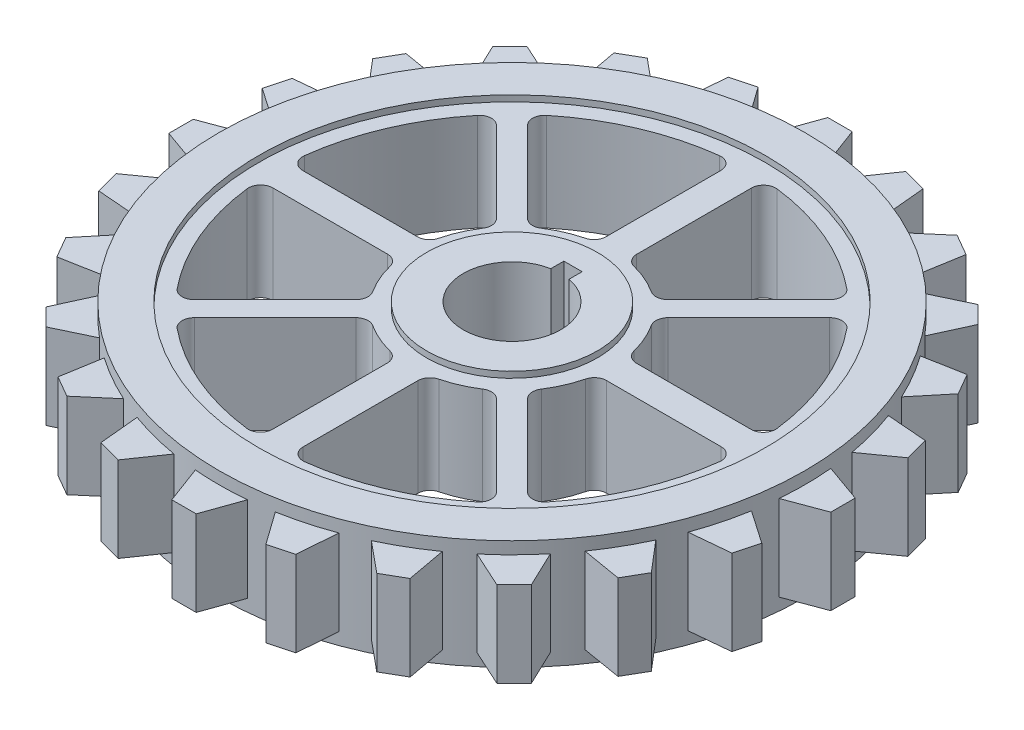
from build123d import *

# Parameters (mm, degrees)
SKETCH1_R           = 41.525000065
BOSS_EXTRUDE1_DEPTH = 9
BOSS_EXTRUDE2_DEPTH = 7
BOSS_EXTRUDE3_DEPTH = 7
BOSS_EXTRUDE4_DEPTH = 7
SKETCH1_11_R        = 14
BOSS_EXTRUDE5_DEPTH = 9
SKETCH1_12_R        = 41.525000065
SKETCH1_12_R_2      = 14
BOSS_EXTRUDE6_DEPTH = 8


with BuildPart() as part:
    # Sketch1 → Boss-Extrude1 (new, symmetric)
    with BuildSketch(Plane(origin=(0, 0, 0), x_dir=(1, 0, 0), z_dir=(0, 1, 0))):
        with BuildLine():
            ThreePointArc((8.078062241, 47.340738711), (6.072143554, 47.639581274), (4.055396381, 47.853467915))
            ThreePointArc((4.055396381, 47.853467915), (-0.198017618, 48.024591829), (-4.449875843, 47.818398512))
            ThreePointArc((-4.449875843, 47.818398512), (-6.464790654, 47.587888302), (-8.46817677, 47.272514355))
            ThreePointArc((-8.46817677, 47.272514355), (-12.62094933, 46.336942813), (-16.674562241, 45.037313478))
            ThreePointArc((-16.674562241, 45.037313478), (-18.561160063, 44.293159386), (-20.414657669, 43.470017064))
            ThreePointArc((-20.414657669, 43.470017064), (-24.183784202, 41.491507721), (-27.762904779, 39.187009959))
            ThreePointArc((-27.762904779, 39.187009959), (-29.392617088, 37.979924855), (-30.969913384, 36.705109948))
            ThreePointArc((-30.969913384, 36.705109948), (-34.098534146, 33.818494945), (-36.959251237, 30.66617647))
            ThreePointArc((-36.959251237, 30.66617647), (-38.221015831, 29.07842121), (-39.414620683, 27.438810246))
            ThreePointArc((-39.414620683, 27.438810246), (-41.689525339, 23.840807627), (-43.636885801, 20.055493733))
            ThreePointArc((-43.636885801, 20.055493733), (-44.444715509, 18.195271215), (-45.173286717, 16.302600971))
            ThreePointArc((-45.173286717, 16.302600971), (-46.439444275, 12.238408667), (-47.340738711, 8.078062241))
            ThreePointArc((-47.340738711, 8.078062241), (-47.639581274, 6.072143554), (-47.853467915, 4.055396381))
            ThreePointArc((-47.853467915, 4.055396381), (-48.024591829, -0.198017618), (-47.818398512, -4.449875843))
            ThreePointArc((-47.818398512, -4.449875843), (-47.587888302, -6.464790654), (-47.272514355, -8.46817677))
            ThreePointArc((-47.272514355, -8.46817677), (-46.336942813, -12.62094933), (-45.037313478, -16.674562241))
            ThreePointArc((-45.037313478, -16.674562241), (-44.293159386, -18.561160063), (-43.470017064, -20.414657669))
            ThreePointArc((-43.470017064, -20.414657669), (-41.491507721, -24.183784202), (-39.187009959, -27.762904779))
            ThreePointArc((-39.187009959, -27.762904779), (-37.979924855, -29.392617088), (-36.705109948, -30.969913384))
            ThreePointArc((-36.705109948, -30.969913384), (-33.818494945, -34.098534146), (-30.66617647, -36.959251237))
            ThreePointArc((-30.66617647, -36.959251237), (-29.07842121, -38.221015831), (-27.438810246, -39.414620683))
            ThreePointArc((-27.438810246, -39.414620683), (-23.840807627, -41.689525339), (-20.055493733, -43.636885801))
            ThreePointArc((-20.055493733, -43.636885801), (-18.195271215, -44.444715509), (-16.302600971, -45.173286717))
            ThreePointArc((-16.302600971, -45.173286717), (-12.238408667, -46.439444275), (-8.078062241, -47.340738711))
            ThreePointArc((-8.078062241, -47.340738711), (-6.072143554, -47.639581274), (-4.055396381, -47.853467915))
            ThreePointArc((-4.055396381, -47.853467915), (0.198017618, -48.024591829), (4.449875843, -47.818398512))
            ThreePointArc((4.449875843, -47.818398512), (6.464790654, -47.587888302), (8.46817677, -47.272514355))
            ThreePointArc((8.46817677, -47.272514355), (12.62094933, -46.336942813), (16.674562241, -45.037313478))
            ThreePointArc((16.674562241, -45.037313478), (18.561160063, -44.293159386), (20.414657669, -43.470017064))
            ThreePointArc((20.414657669, -43.470017064), (24.183784202, -41.491507721), (27.762904779, -39.187009959))
            ThreePointArc((27.762904779, -39.187009959), (29.392617088, -37.979924855), (30.969913384, -36.705109948))
            ThreePointArc((30.969913384, -36.705109948), (34.098534146, -33.818494945), (36.959251237, -30.66617647))
            ThreePointArc((36.959251237, -30.66617647), (38.221015831, -29.07842121), (39.414620683, -27.438810246))
            ThreePointArc((39.414620683, -27.438810246), (41.689525339, -23.840807627), (43.636885801, -20.055493733))
            ThreePointArc((43.636885801, -20.055493733), (44.444715509, -18.195271215), (45.173286717, -16.302600971))
            ThreePointArc((45.173286717, -16.302600971), (46.439444275, -12.238408667), (47.340738711, -8.078062241))
            ThreePointArc((47.340738711, -8.078062241), (47.639581274, -6.072143554), (47.853467915, -4.055396381))
            ThreePointArc((47.853467915, -4.055396381), (47.982097865, -2.029511215), (48.025000065, 0))
            ThreePointArc((48.025000065, 0), (47.973321872, 2.227334686), (47.818398512, 4.449875843))
            ThreePointArc((47.818398512, 4.449875843), (47.587888302, 6.464790654), (47.272514355, 8.46817677))
            ThreePointArc((47.272514355, 8.46817677), (46.336942813, 12.62094933), (45.037313478, 16.674562241))
            ThreePointArc((45.037313478, 16.674562241), (44.293159386, 18.561160063), (43.470017064, 20.414657669))
            ThreePointArc((43.470017064, 20.414657669), (41.491507721, 24.183784202), (39.187009959, 27.762904779))
            ThreePointArc((39.187009959, 27.762904779), (37.979924855, 29.392617088), (36.705109948, 30.969913384))
            ThreePointArc((36.705109948, 30.969913384), (33.818494945, 34.098534146), (30.66617647, 36.959251237))
            ThreePointArc((30.66617647, 36.959251237), (29.07842121, 38.221015831), (27.438810246, 39.414620683))
            ThreePointArc((27.438810246, 39.414620683), (23.840807627, 41.689525339), (20.055493733, 43.636885801))
            ThreePointArc((20.055493733, 43.636885801), (18.195271215, 44.444715509), (16.302600971, 45.173286717))
            ThreePointArc((16.302600971, 45.173286717), (12.238408667, 46.439444275), (8.078062241, 47.340738711))
        make_face()
        Circle(SKETCH1_R, mode=Mode.SUBTRACT)
    extrude(amount=BOSS_EXTRUDE1_DEPTH, both=True)

    # Sketch1_8 → Boss-Extrude2 (add, symmetric)
    with BuildSketch(Plane(origin=(0, 0, 0), x_dir=(1, 0, 0), z_dir=(0, 1, 0))):
        with BuildLine():
            Line((11.813793694, 52.765299234), (8.078062241, 47.340738711))
            ThreePointArc((8.078062241, 47.340738711), (12.238408667, 46.439444275), (16.302600971, 45.173286717))
            Line((16.302600971, 45.173286717), (15.677497, 51.730023054))
            Line((15.677497, 51.730023054), (11.813793694, 52.765299234))
        make_face()
        with BuildLine():
            Line((25.067912798, 47.909730459), (20.055493733, 43.636885801))
            ThreePointArc((20.055493733, 43.636885801), (23.840807627, 41.689525339), (27.438810246, 39.414620683))
            Line((27.438810246, 39.414620683), (28.532014413, 45.909730459))
            Line((28.532014413, 45.909730459), (25.067912798, 47.909730459))
        make_face()
        with BuildLine():
            Line((36.613695072, 39.789192728), (30.66617647, 36.959251237))
            ThreePointArc((30.66617647, 36.959251237), (33.818494945, 34.098534146), (36.705109948, 30.969913384))
            Line((36.705109948, 30.969913384), (39.442122196, 36.960765603))
            Line((39.442122196, 36.960765603), (36.613695072, 39.789192728))
        make_face()
        with BuildLine():
            Line((45.664314533, 28.957087267), (39.187009959, 27.762904779))
            ThreePointArc((39.187009959, 27.762904779), (41.491507721, 24.183784202), (43.470017064, 20.414657669))
            Line((43.470017064, 20.414657669), (47.664314533, 25.492985652))
            Line((47.664314533, 25.492985652), (45.664314533, 28.957087267))
        make_face()
        with BuildLine():
            Line((51.602986422, 16.151604163), (45.037313478, 16.674562241))
            ThreePointArc((45.037313478, 16.674562241), (46.336942813, 12.62094933), (47.272514355, 8.46817677))
            Line((47.272514355, 8.46817677), (52.638262603, 12.287900858))
            Line((52.638262603, 12.287900858), (51.602986422, 16.151604163))
        make_face()
    extrude(amount=BOSS_EXTRUDE2_DEPTH, both=True)

    # Sketch1_9 → Boss-Extrude3 (add, symmetric)
    with BuildSketch(Plane(origin=(0, 0, 0), x_dir=(1, 0, 0), z_dir=(0, 1, 0))):
        with BuildLine():
            Line((1.754584074, 54.025000065), (-2.245415926, 54.025000065))
            Line((-2.245415926, 54.025000065), (-4.449875843, 47.818398512))
            ThreePointArc((-4.449875843, 47.818398512), (-0.198017618, 48.024591829), (4.055396381, 47.853467915))
            Line((4.055396381, 47.853467915), (1.754584074, 54.025000065))
        make_face()
        with BuildLine():
            ThreePointArc((-16.674562241, 45.037313478), (-12.62094933, 46.336942813), (-8.46817677, 47.272514355))
            Line((-8.46817677, 47.272514355), (-12.287900858, 52.638262603))
            Line((-12.287900858, 52.638262603), (-16.151604163, 51.602986422))
            Line((-16.151604163, 51.602986422), (-16.674562241, 45.037313478))
        make_face()
        with BuildLine():
            ThreePointArc((-27.762904779, 39.187009959), (-24.183784202, 41.491507721), (-20.414657669, 43.470017064))
            Line((-20.414657669, 43.470017064), (-25.492985652, 47.664314533))
            Line((-25.492985652, 47.664314533), (-28.957087267, 45.664314533))
            Line((-28.957087267, 45.664314533), (-27.762904779, 39.187009959))
        make_face()
        with BuildLine():
            ThreePointArc((-36.959251237, 30.66617647), (-34.098534146, 33.818494945), (-30.969913384, 36.705109948))
            Line((-30.969913384, 36.705109948), (-36.960765603, 39.442122196))
            Line((-36.960765603, 39.442122196), (-39.789192728, 36.613695072))
            Line((-39.789192728, 36.613695072), (-36.959251237, 30.66617647))
        make_face()
        with BuildLine():
            ThreePointArc((-43.636885801, 20.055493733), (-41.689525339, 23.840807627), (-39.414620683, 27.438810246))
            Line((-39.414620683, 27.438810246), (-45.909730459, 28.532014413))
            Line((-45.909730459, 28.532014413), (-47.909730459, 25.067912798))
            Line((-47.909730459, 25.067912798), (-43.636885801, 20.055493733))
        make_face()
        with BuildLine():
            ThreePointArc((-47.340738711, 8.078062241), (-46.439444275, 12.238408667), (-45.173286717, 16.302600971))
            Line((-45.173286717, 16.302600971), (-51.730023054, 15.677497))
            Line((-51.730023054, 15.677497), (-52.765299234, 11.813793694))
            Line((-52.765299234, 11.813793694), (-47.340738711, 8.078062241))
        make_face()
        with BuildLine():
            ThreePointArc((-47.818398512, -4.449875843), (-48.024591829, -0.198017618), (-47.853467915, 4.055396381))
            Line((-47.853467915, 4.055396381), (-54.025000065, 1.754584074))
            Line((-54.025000065, 1.754584074), (-54.025000065, -2.245415926))
            Line((-54.025000065, -2.245415926), (-47.818398512, -4.449875843))
        make_face()
        with BuildLine():
            ThreePointArc((-45.037313478, -16.674562241), (-46.336942813, -12.62094933), (-47.272514355, -8.46817677))
            Line((-47.272514355, -8.46817677), (-52.638262603, -12.287900858))
            Line((-52.638262603, -12.287900858), (-51.602986422, -16.151604163))
            Line((-51.602986422, -16.151604163), (-45.037313478, -16.674562241))
        make_face()
        with BuildLine():
            Line((52.765299234, -11.813793694), (47.340738711, -8.078062241))
            ThreePointArc((47.340738711, -8.078062241), (46.439444275, -12.238408667), (45.173286717, -16.302600971))
            Line((45.173286717, -16.302600971), (51.730023054, -15.677497))
            Line((51.730023054, -15.677497), (52.765299234, -11.813793694))
        make_face()
        with BuildLine():
            ThreePointArc((-39.187009959, -27.762904779), (-41.491507721, -24.183784202), (-43.470017064, -20.414657669))
            Line((-43.470017064, -20.414657669), (-47.664314533, -25.492985652))
            Line((-47.664314533, -25.492985652), (-45.664314533, -28.957087267))
            Line((-45.664314533, -28.957087267), (-39.187009959, -27.762904779))
        make_face()
        with BuildLine():
            Line((47.909730459, -25.067912798), (43.636885801, -20.055493733))
            ThreePointArc((43.636885801, -20.055493733), (41.689525339, -23.840807627), (39.414620683, -27.438810246))
            Line((39.414620683, -27.438810246), (45.909730459, -28.532014413))
            Line((45.909730459, -28.532014413), (47.909730459, -25.067912798))
        make_face()
        with BuildLine():
            ThreePointArc((-30.66617647, -36.959251237), (-33.818494945, -34.098534146), (-36.705109948, -30.969913384))
            Line((-36.705109948, -30.969913384), (-39.442122196, -36.960765603))
            Line((-39.442122196, -36.960765603), (-36.613695072, -39.789192728))
            Line((-36.613695072, -39.789192728), (-30.66617647, -36.959251237))
        make_face()
        with BuildLine():
            Line((39.789192728, -36.613695072), (36.959251237, -30.66617647))
            ThreePointArc((36.959251237, -30.66617647), (34.098534146, -33.818494945), (30.969913384, -36.705109948))
            Line((30.969913384, -36.705109948), (36.960765603, -39.442122196))
            Line((36.960765603, -39.442122196), (39.789192728, -36.613695072))
        make_face()
        with BuildLine():
            ThreePointArc((-20.055493733, -43.636885801), (-23.840807627, -41.689525339), (-27.438810246, -39.414620683))
            Line((-27.438810246, -39.414620683), (-28.532014413, -45.909730459))
            Line((-28.532014413, -45.909730459), (-25.067912798, -47.909730459))
            Line((-25.067912798, -47.909730459), (-20.055493733, -43.636885801))
        make_face()
        with BuildLine():
            Line((28.957087267, -45.664314533), (27.762904779, -39.187009959))
            ThreePointArc((27.762904779, -39.187009959), (24.183784202, -41.491507721), (20.414657669, -43.470017064))
            Line((20.414657669, -43.470017064), (25.492985652, -47.664314533))
            Line((25.492985652, -47.664314533), (28.957087267, -45.664314533))
        make_face()
        with BuildLine():
            ThreePointArc((-8.078062241, -47.340738711), (-12.238408667, -46.439444275), (-16.302600971, -45.173286717))
            Line((-16.302600971, -45.173286717), (-15.677497, -51.730023054))
            Line((-15.677497, -51.730023054), (-11.813793694, -52.765299234))
            Line((-11.813793694, -52.765299234), (-8.078062241, -47.340738711))
        make_face()
        with BuildLine():
            Line((16.151604163, -51.602986422), (16.674562241, -45.037313478))
            ThreePointArc((16.674562241, -45.037313478), (12.62094933, -46.336942813), (8.46817677, -47.272514355))
            Line((8.46817677, -47.272514355), (12.287900858, -52.638262603))
            Line((12.287900858, -52.638262603), (16.151604163, -51.602986422))
        make_face()
    extrude(amount=BOSS_EXTRUDE3_DEPTH, both=True)

    # Sketch1_10 → Boss-Extrude4 (add, symmetric)
    with BuildSketch(Plane(origin=(0, 0, 0), x_dir=(1, 0, 0), z_dir=(0, 1, 0))):
        with BuildLine():
            Line((54.025000065, 2.245415926), (47.818398512, 4.449875843))
            ThreePointArc((47.818398512, 4.449875843), (48.024591829, 0.198017618), (47.853467915, -4.055396381))
            Line((47.853467915, -4.055396381), (54.025000065, -1.754584074))
            Line((54.025000065, -1.754584074), (54.025000065, 2.245415926))
        make_face()
        with BuildLine():
            ThreePointArc((4.449875843, -47.818398512), (0.198017618, -48.024591829), (-4.055396381, -47.853467915))
            Line((-4.055396381, -47.853467915), (-1.754584074, -54.025000065))
            Line((-1.754584074, -54.025000065), (2.245415926, -54.025000065))
            Line((2.245415926, -54.025000065), (4.449875843, -47.818398512))
        make_face()
    extrude(amount=BOSS_EXTRUDE4_DEPTH, both=True)



with BuildPart() as body_2:
    # Sketch1_11 → Boss-Extrude5 (new, symmetric)
    with BuildSketch(Plane(origin=(0, 0, 0), x_dir=(1, 0, 0), z_dir=(0, 1, 0))):
        Circle(SKETCH1_11_R)
        with BuildLine():
            ThreePointArc((1.5, 7.858116823), (0, -8), (-1.5, 7.858116823))
            Line((-1.5, 7.858116823), (-1.5, 10))
            Line((-1.5, 10), (1.5, 10))
            Line((1.5, 10), (1.5, 7.858116823))
        make_face(mode=Mode.SUBTRACT)
    extrude(amount=BOSS_EXTRUDE5_DEPTH, both=True)


with BuildPart() as part_1:
    add(part.part)

    add(body_2.part)  # Boss-Extrude6 merges body 2
    # Sketch1_12 → Boss-Extrude6 (add, symmetric)
    with BuildSketch(Plane(origin=(0, 0, 0), x_dir=(1, 0, 0), z_dir=(0, 1, 0))):
        Circle(SKETCH1_12_R)
        with BuildLine():
            Line((-24.766430072, -27.317730576), (-11.526288377, -14.077588881))
            ThreePointArc((-11.526288377, -14.077588881), (-10.318806071, -13.502515589), (-9.018877537, -13.81701299))
            ThreePointArc((-9.018877537, -13.81701299), (-6.6073444, -15.119292311), (-4.013513514, -16.004427802))
            ThreePointArc((-4.013513514, -16.004427802), (-2.923140309, -16.714109074), (-2.5, -17.944358445))
            Line((-2.5, -17.944358445), (-2.5, -36.75051877))
            ThreePointArc((-2.5, -36.75051877), (-3.174511034, -38.248209993), (-4.743079, -38.735691961))
            ThreePointArc((-4.743079, -38.735691961), (-15.274561015, -35.911535973), (-24.613646163, -30.283973528))
            ThreePointArc((-24.613646163, -30.283973528), (-25.349568749, -28.834822859), (-24.766430072, -27.317730576))
        make_face(mode=Mode.SUBTRACT)
        with BuildLine():
            Line((-36.755957512, -2.455358262), (-17.9554945, -2.455358262))
            ThreePointArc((-17.9554945, -2.455358262), (-16.723285246, -2.880029613), (-16.01435996, -3.97369791))
            ThreePointArc((-16.01435996, -3.97369791), (-15.127496898, -6.588538352), (-13.81701299, -9.018877537))
            ThreePointArc((-13.81701299, -9.018877537), (-13.502515589, -10.318806071), (-14.077588881, -11.526288377))
            Line((-14.077588881, -11.526288377), (-27.317730576, -24.766430072))
            ThreePointArc((-27.317730576, -24.766430072), (-28.834822859, -25.349568749), (-30.283973528, -24.613646163))
            ThreePointArc((-30.283973528, -24.613646163), (-35.92080585, -15.252748513), (-38.741424491, -4.696025825))
            ThreePointArc((-38.741424491, -4.696025825), (-38.252843467, -3.128959967), (-36.755957512, -2.455358262))
        make_face(mode=Mode.SUBTRACT)
        with BuildLine():
            ThreePointArc((4.743079, -38.735691961), (3.174511034, -38.248209993), (2.5, -36.75051877))
            Line((2.5, -36.75051877), (2.5, -17.944358445))
            ThreePointArc((2.5, -17.944358445), (2.923140309, -16.714109074), (4.013513514, -16.004427802))
            ThreePointArc((4.013513514, -16.004427802), (6.6073444, -15.119292311), (9.018877537, -13.81701299))
            ThreePointArc((9.018877537, -13.81701299), (10.318806071, -13.502515589), (11.526288377, -14.077588881))
            Line((11.526288377, -14.077588881), (24.766430072, -27.317730576))
            ThreePointArc((24.766430072, -27.317730576), (25.349568749, -28.834822859), (24.613646163, -30.283973528))
            ThreePointArc((24.613646163, -30.283973528), (15.274561015, -35.911535973), (4.743079, -38.735691961))
        make_face(mode=Mode.SUBTRACT)
        with BuildLine():
            Line((27.317730576, -24.766430072), (14.077588881, -11.526288377))
            ThreePointArc((14.077588881, -11.526288377), (13.502515589, -10.318806071), (13.81701299, -9.018877537))
            ThreePointArc((13.81701299, -9.018877537), (15.127496898, -6.588538352), (16.01435996, -3.97369791))
            ThreePointArc((16.01435996, -3.97369791), (16.723285246, -2.880029613), (17.9554945, -2.455358262))
            Line((17.9554945, -2.455358262), (36.755957512, -2.455358262))
            ThreePointArc((36.755957512, -2.455358262), (38.252843467, -3.128959967), (38.741424491, -4.696025825))
            ThreePointArc((38.741424491, -4.696025825), (35.92080585, -15.252748513), (30.283973528, -24.613646163))
            ThreePointArc((30.283973528, -24.613646163), (28.834822859, -25.349568749), (27.317730576, -24.766430072))
        make_face(mode=Mode.SUBTRACT)
        Circle(SKETCH1_12_R_2, mode=Mode.SUBTRACT)
        with BuildLine():
            ThreePointArc((-16.01435996, 3.97369791), (-16.723285246, 2.880029613), (-17.9554945, 2.455358262))
            Line((-17.9554945, 2.455358262), (-36.755957512, 2.455358262))
            ThreePointArc((-36.755957512, 2.455358262), (-38.252843467, 3.128959967), (-38.741424491, 4.696025825))
            ThreePointArc((-38.741424491, 4.696025825), (-35.92080585, 15.252748513), (-30.283973528, 24.613646163))
            ThreePointArc((-30.283973528, 24.613646163), (-28.834822859, 25.349568749), (-27.317730576, 24.766430072))
            Line((-27.317730576, 24.766430072), (-14.077588881, 11.526288377))
            ThreePointArc((-14.077588881, 11.526288377), (-13.502515589, 10.318806071), (-13.81701299, 9.018877537))
            ThreePointArc((-13.81701299, 9.018877537), (-15.127496898, 6.588538352), (-16.01435996, 3.97369791))
        make_face(mode=Mode.SUBTRACT)
        with BuildLine():
            ThreePointArc((-4.743079, 38.735691961), (-3.174511034, 38.248209993), (-2.5, 36.75051877))
            Line((-2.5, 36.75051877), (-2.5, 17.944358445))
            ThreePointArc((-2.5, 17.944358445), (-2.923140309, 16.714109074), (-4.013513514, 16.004427802))
            ThreePointArc((-4.013513514, 16.004427802), (-6.6073444, 15.119292311), (-9.018877537, 13.81701299))
            ThreePointArc((-9.018877537, 13.81701299), (-10.318806071, 13.502515589), (-11.526288377, 14.077588881))
            Line((-11.526288377, 14.077588881), (-24.766430072, 27.317730576))
            ThreePointArc((-24.766430072, 27.317730576), (-25.349568749, 28.834822859), (-24.613646163, 30.283973528))
            ThreePointArc((-24.613646163, 30.283973528), (-15.274561015, 35.911535973), (-4.743079, 38.735691961))
        make_face(mode=Mode.SUBTRACT)
        with BuildLine():
            Line((36.755957512, 2.455358262), (17.9554945, 2.455358262))
            ThreePointArc((17.9554945, 2.455358262), (16.723285246, 2.880029613), (16.01435996, 3.97369791))
            ThreePointArc((16.01435996, 3.97369791), (15.127496898, 6.588538352), (13.81701299, 9.018877537))
            ThreePointArc((13.81701299, 9.018877537), (13.502515589, 10.318806071), (14.077588881, 11.526288377))
            Line((14.077588881, 11.526288377), (27.317730576, 24.766430072))
            ThreePointArc((27.317730576, 24.766430072), (28.834822859, 25.349568749), (30.283973528, 24.613646163))
            ThreePointArc((30.283973528, 24.613646163), (35.92080585, 15.252748513), (38.741424491, 4.696025825))
            ThreePointArc((38.741424491, 4.696025825), (38.252843467, 3.128959967), (36.755957512, 2.455358262))
        make_face(mode=Mode.SUBTRACT)
        with BuildLine():
            Line((2.5, 17.944358445), (2.5, 36.75051877))
            ThreePointArc((2.5, 36.75051877), (3.174511034, 38.248209993), (4.743079, 38.735691961))
            ThreePointArc((4.743079, 38.735691961), (15.274561015, 35.911535973), (24.613646163, 30.283973528))
            ThreePointArc((24.613646163, 30.283973528), (25.349568749, 28.834822859), (24.766430072, 27.317730576))
            Line((24.766430072, 27.317730576), (11.526288377, 14.077588881))
            ThreePointArc((11.526288377, 14.077588881), (10.318806071, 13.502515589), (9.018877537, 13.81701299))
            ThreePointArc((9.018877537, 13.81701299), (6.6073444, 15.119292311), (4.013513514, 16.004427802))
            ThreePointArc((4.013513514, 16.004427802), (2.923140309, 16.714109074), (2.5, 17.944358445))
        make_face(mode=Mode.SUBTRACT)
    extrude(amount=BOSS_EXTRUDE6_DEPTH, both=True)


solid = part_1.part
